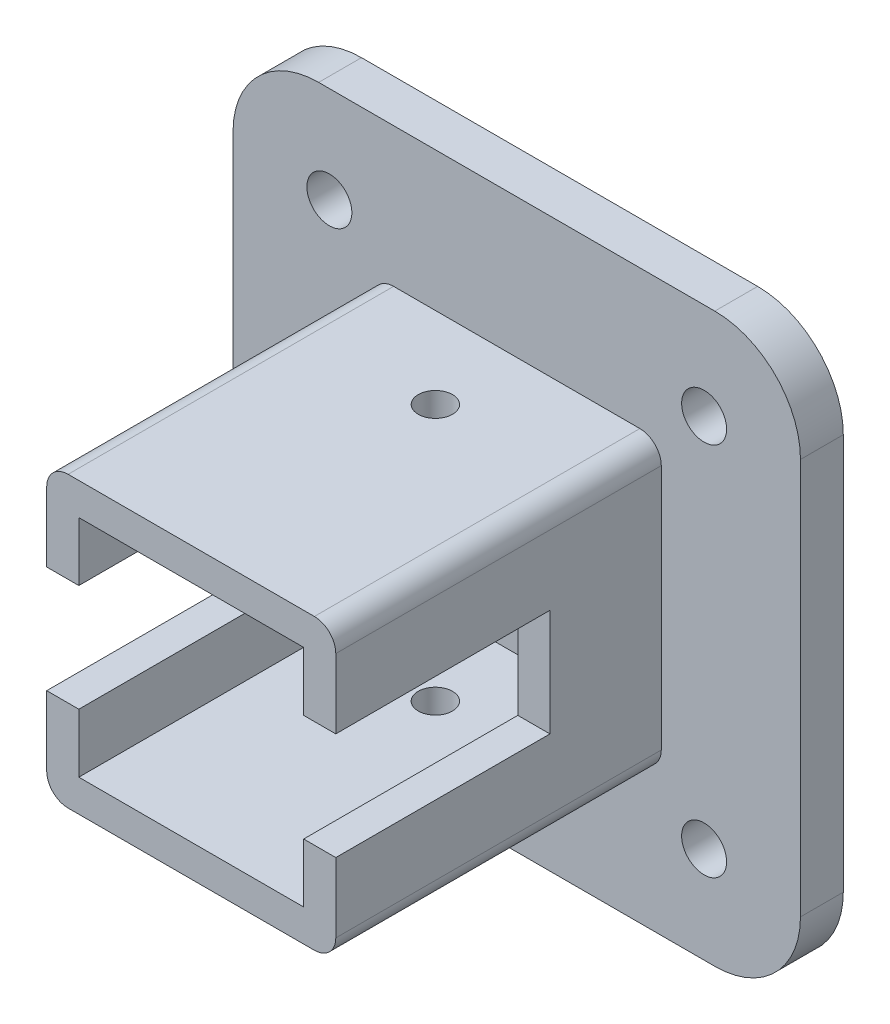
from build123d import *

# Parameters (mm, degrees)
SKETCH1_W           = 27
SKETCH1_H           = 27
SKETCH1_W_2         = 21
SKETCH1_H_2         = 21
BOSS_EXTRUDE1_DEPTH = 15.2
SKETCH2_R           = 1.6
CUT_EXTRUDE1_DEPTH  = 34.797780992
SKETCH5_R           = 2.1
SKETCH5_W           = 27
SKETCH5_H           = 27
SKETCH5_W_2         = 21
SKETCH5_H_2         = 21
BOSS_EXTRUDE3_DEPTH = 4
FILLET2_R           = 2
BOSS_EXTRUDE5_DEPTH = 4
SKETCH8_W           = 21
SKETCH8_H           = 21
BOSS_EXTRUDE7_DEPTH = 15.2
SKETCH9_W           = 20
SKETCH9_H           = 10
CUT_EXTRUDE2_DEPTH  = 57.801496459


with BuildPart() as part:
    # Sketch1 → Boss-Extrude1 (new body)
    with BuildSketch(Plane.XY):
        Rectangle(SKETCH1_W, SKETCH1_H)
        Rectangle(SKETCH1_W_2, SKETCH1_H_2, mode=Mode.SUBTRACT)
    extrude(amount=BOSS_EXTRUDE1_DEPTH)

    # Sketch2 → Cut-Extrude1 (cut, through all)
    with BuildSketch(Plane.XZ.offset(13.5)):
        with Locations((0, 7.6)):
            Circle(SKETCH2_R)
    extrude(amount=-CUT_EXTRUDE1_DEPTH, mode=Mode.SUBTRACT)

    # Sketch5 → Boss-Extrude3 (add)
    with BuildSketch(Plane(origin=(0, 0, 0), x_dir=(-1, 0, 0), z_dir=(0, 0, -1))):
        with BuildLine():
            Line((18.5, 21.5), (-18.5, 21.5))
            ThreePointArc((-18.5, 21.5), (-20.621320344, 20.621320344), (-21.5, 18.5))
            Line((-21.5, 18.5), (-21.5, -18.5))
            ThreePointArc((-21.5, -18.5), (-20.621320344, -20.621320344), (-18.5, -21.5))
            Line((-18.5, -21.5), (18.5, -21.5))
            ThreePointArc((18.5, -21.5), (20.621320344, -20.621320344), (21.5, -18.5))
            Line((21.5, -18.5), (21.5, 18.5))
            ThreePointArc((21.5, 18.5), (20.621320344, 20.621320344), (18.5, 21.5))
        make_face()
        with Locations((-17.5, 17.5)):
            Circle(SKETCH5_R, mode=Mode.SUBTRACT)
        with Locations((-17.5, -17.5)):
            Circle(SKETCH5_R, mode=Mode.SUBTRACT)
        with Locations((17.5, -17.5)):
            Circle(SKETCH5_R, mode=Mode.SUBTRACT)
        with Locations((17.5, 17.5)):
            Circle(SKETCH5_R, mode=Mode.SUBTRACT)
        Rectangle(SKETCH5_W, SKETCH5_H, mode=Mode.SUBTRACT)
        Rectangle(SKETCH5_W, SKETCH5_H)
        Rectangle(SKETCH5_W_2, SKETCH5_H_2, mode=Mode.SUBTRACT)
        Rectangle(SKETCH5_W_2, SKETCH5_H_2)
    extrude(amount=BOSS_EXTRUDE3_DEPTH)

    # Fillet2
    fillet2_edges = [part.edges().sort_by_distance(p)[0] for p in [
        (13.5, -13.5, 7.6),
        (-13.5, -13.5, 7.6),
        (-13.5, 13.5, 7.6),
        (13.5, 13.5, 7.6),
    ]]
    fillet(fillet2_edges, radius=FILLET2_R)

    # Sketch7 → Boss-Extrude5 (add)
    with BuildSketch(Plane.XY):
        with BuildLine():
            Line((18.5, 26.5), (-18.5, 26.5))
            ThreePointArc((-18.5, 26.5), (-24.156854249, 24.156854249), (-26.5, 18.5))
            Line((-26.5, 18.5), (-26.5, -18.5))
            ThreePointArc((-26.5, -18.5), (-24.156854249, -24.156854249), (-18.5, -26.5))
            Line((-18.5, -26.5), (18.5, -26.5))
            ThreePointArc((18.5, -26.5), (24.156854249, -24.156854249), (26.5, -18.5))
            Line((26.5, -18.5), (26.5, 18.5))
            ThreePointArc((26.5, 18.5), (24.156854249, 24.156854249), (18.5, 26.5))
        make_face()
        with BuildLine():
            Line((18.5, 21.5), (-18.5, 21.5))
            ThreePointArc((-18.5, 21.5), (-20.621320344, 20.621320344), (-21.5, 18.5))
            Line((-21.5, 18.5), (-21.5, -18.5))
            ThreePointArc((-21.5, -18.5), (-20.621320344, -20.621320344), (-18.5, -21.5))
            Line((-18.5, -21.5), (18.5, -21.5))
            ThreePointArc((18.5, -21.5), (20.621320344, -20.621320344), (21.5, -18.5))
            Line((21.5, -18.5), (21.5, 18.5))
            ThreePointArc((21.5, 18.5), (20.621320344, 20.621320344), (18.5, 21.5))
        make_face(mode=Mode.SUBTRACT)
    extrude(amount=-BOSS_EXTRUDE5_DEPTH)

    # Sketch8 → Boss-Extrude7 (add)
    with BuildSketch(Plane.XY.offset(15.2)):
        with BuildLine():
            ThreePointArc((-11.5, 13.5), (-12.914213562, 12.914213562), (-13.5, 11.5))
            Line((-13.5, 11.5), (-13.5, -11.5))
            ThreePointArc((-13.5, -11.5), (-12.914213562, -12.914213562), (-11.5, -13.5))
            Line((-11.5, -13.5), (11.5, -13.5))
            ThreePointArc((11.5, -13.5), (12.914213562, -12.914213562), (13.5, -11.5))
            Line((13.5, -11.5), (13.5, 11.5))
            ThreePointArc((13.5, 11.5), (12.914213562, 12.914213562), (11.5, 13.5))
            Line((11.5, 13.5), (-11.5, 13.5))
        make_face()
        Rectangle(SKETCH8_W, SKETCH8_H, mode=Mode.SUBTRACT)
    extrude(amount=BOSS_EXTRUDE7_DEPTH)

    # Sketch9 → Cut-Extrude2 (cut, through all)
    with BuildSketch(Plane(origin=(13.5, 0, 0), x_dir=(0, 0, -1), z_dir=(1, 0, 0))):
        with Locations((-20.4, 0)):
            Rectangle(SKETCH9_W, SKETCH9_H)
    extrude(amount=-CUT_EXTRUDE2_DEPTH, mode=Mode.SUBTRACT)


solid = part.part
